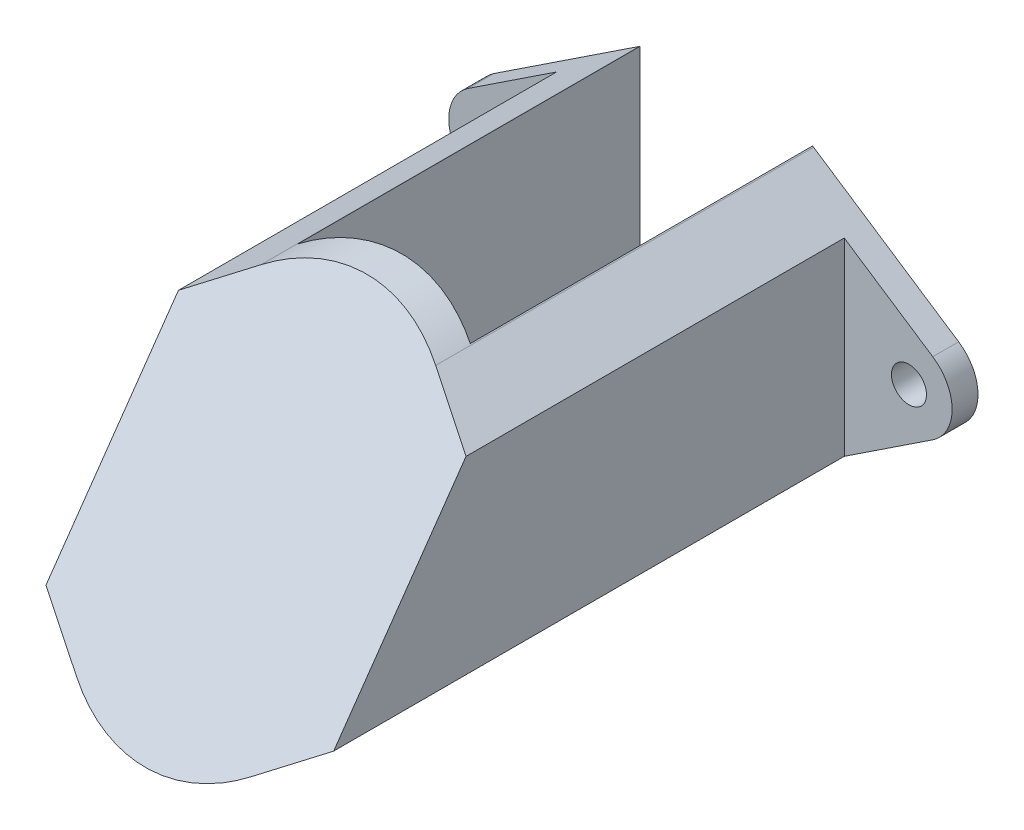
from build123d import *

# Parameters (mm, degrees)
BOSS_EXTRUDE1_DEPTH     = 45
SKETCH3_OUTSIDE_W       = 59.222
SKETCH3_OUTSIDE_H       = 36.222
CUT_EXTRUDE1_DEPTH      = 18.5
CUT_EXTRUDE1_DEPTH_BACK = 18.5
CUT_EXTRUDE2_START      = -1.8
SKETCH5_OUTSIDE_W       = 48.562
SKETCH5_OUTSIDE_H       = 35.562
SKETCH5_OUTSIDE_W_2     = 20
SKETCH5_OUTSIDE_H_2     = 24.414034222
CUT_EXTRUDE2_DEPTH      = 39.604565841
F_2_CLEARANCE_HOLE1_D   = 2.4384
CUT_EXTRUDE3_START      = -2
SKETCH8_W               = 12
SKETCH8_H               = 64.371558748
CUT_EXTRUDE3_DEPTH      = 32.097482707


with BuildPart() as part:
    # Sketch1 → Boss-Extrude1 (new body)
    with BuildSketch(Plane.XY):
        with BuildLine():
            Line((-16.155172414, 2.502079991), (-6.068965517, 9.1742933))
            ThreePointArc((-6.068965517, 9.1742933), (0, 11), (6.068965517, 9.1742933))
            Line((6.068965517, 9.1742933), (16.155172414, 2.502079991))
            ThreePointArc((16.155172414, 2.502079991), (17.5, 0), (16.155172414, -2.502079991))
            Line((16.155172414, -2.502079991), (6.068965517, -9.1742933))
            ThreePointArc((6.068965517, -9.1742933), (0, -11), (-6.068965517, -9.1742933))
            Line((-6.068965517, -9.1742933), (-16.155172414, -2.502079991))
            ThreePointArc((-16.155172414, -2.502079991), (-17.5, 0), (-16.155172414, 2.502079991))
        make_face()
    extrude(amount=BOSS_EXTRUDE1_DEPTH)

    # Sketch3 outside → Cut-Extrude1 (cut, two sides)
    with BuildSketch(Plane(origin=(0, 0, 0), x_dir=(0, 0, -1), z_dir=(1, 0, 0))) as cut_extrude1_sk:
        with Locations((-22.5, 0)):
            Rectangle(SKETCH3_OUTSIDE_W, SKETCH3_OUTSIDE_H)
        Polygon((-25, 11), (-40.404565841, -11), (0, -11), (0, 11), align=None, mode=Mode.SUBTRACT)
    extrude(amount=CUT_EXTRUDE1_DEPTH, mode=Mode.SUBTRACT)
    extrude(cut_extrude1_sk.sketch, amount=-CUT_EXTRUDE1_DEPTH_BACK, mode=Mode.SUBTRACT)

    # Sketch5 outside → Cut-Extrude2 (cut, through all)
    with BuildSketch(Plane(origin=(0, 0, 0), x_dir=(-1, 0, 0), z_dir=(0, 0, -1)).offset(CUT_EXTRUDE2_START)):
        Rectangle(SKETCH5_OUTSIDE_W, SKETCH5_OUTSIDE_H)
        Rectangle(SKETCH5_OUTSIDE_W_2, SKETCH5_OUTSIDE_H_2, mode=Mode.SUBTRACT)
    extrude(amount=-CUT_EXTRUDE2_DEPTH, mode=Mode.SUBTRACT)

    # #2 Clearance Hole1 (through all)
    with Locations(Plane.XY.offset(1.8)):
        with Locations((14.5, 0), (-14.5, 0)):
            Hole(F_2_CLEARANCE_HOLE1_D / 2)

    # Sketch8 → Cut-Extrude3 (cut, through all)
    with BuildSketch(Plane(origin=(0, 15.365046972, 21.943561206), x_dir=(1, 0, 0), z_dir=(0, 0.573576436, 0.819152044)).offset(CUT_EXTRUDE3_START)):
        Rectangle(SKETCH8_W, SKETCH8_H)
    extrude(amount=-CUT_EXTRUDE3_DEPTH, mode=Mode.SUBTRACT)


solid = part.part
